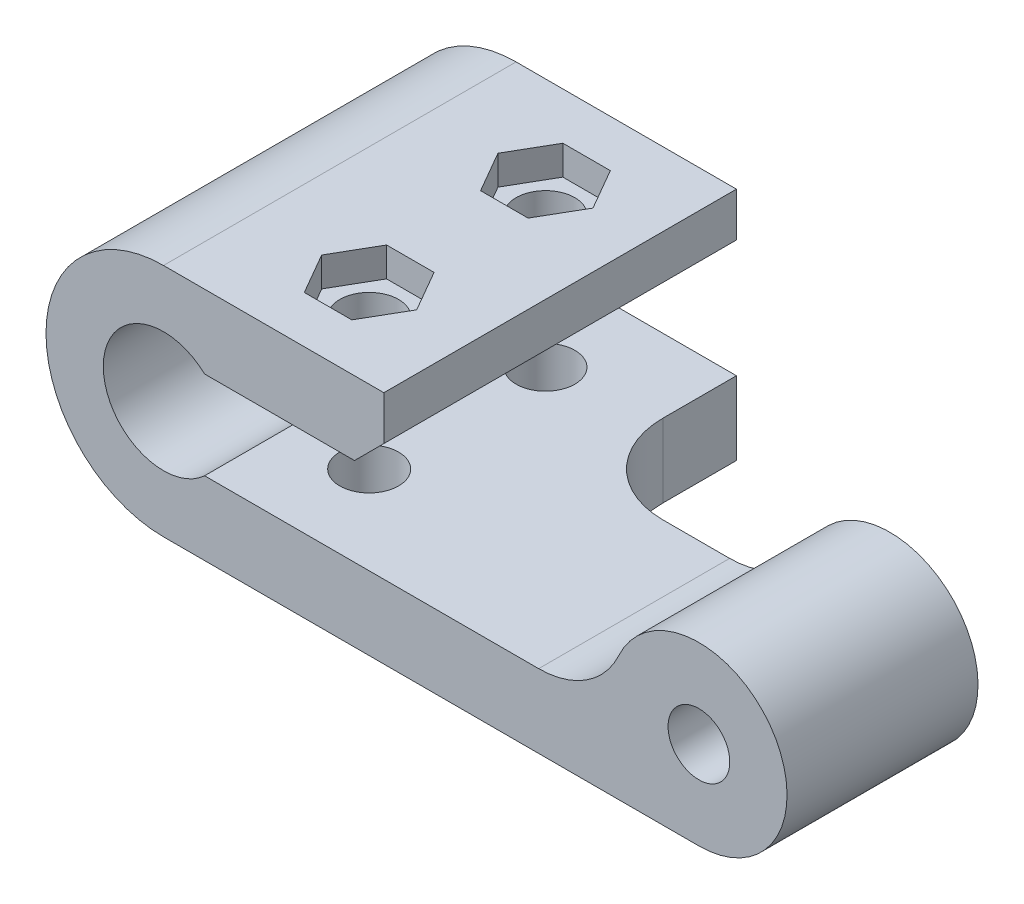
from build123d import *

# Parameters (mm, degrees)
SKETCH1_R           = 2.1
BOSS_EXTRUDE1_DEPTH = 24
SKETCH2_R           = 2
CUT_EXTRUDE1_DEPTH  = 17
CUT_EXTRUDE2_DEPTH  = 2
CUT_EXTRUDE3_DEPTH  = 5
CHAMFER1_SIZE       = 2


with BuildPart() as part:
    # Sketch1 → Boss-Extrude1 (new body)
    with BuildSketch(Plane.XY):
        with BuildLine():
            Line((2.794637722, 3), (15, 3))
            Line((15, 3), (15, 8))
            Line((15, 8), (0, 8))
            ThreePointArc((0, 8), (-8, 0), (0, -8))
            Line((0, -8), (36.445164288, -8))
            ThreePointArc((36.445164288, -8), (41.494916757, 1.240370349), (30.990808231, 0.5))
            ThreePointArc((30.990808231, 0.5), (28.776822523, -2.049752469), (25.536452174, -3))
            Line((25.536452174, -3), (2.794637722, -3))
            ThreePointArc((2.794637722, -3), (-4.1, 0), (2.794637722, 3))
        make_face()
        with Locations((36.445164288, -2)):
            Circle(SKETCH1_R, mode=Mode.SUBTRACT)
    extrude(amount=BOSS_EXTRUDE1_DEPTH)

    # Sketch2 → Cut-Extrude1 (cut, through all)
    with BuildSketch(Plane.XZ.offset(8)):
        with Locations((8, 18)):
            Circle(SKETCH2_R)
        with Locations((8, 6)):
            Circle(SKETCH2_R)
        with BuildLine():
            Line((15, 5), (15, 0))
            Line((15, 0), (45.871149595, 0))
            Line((45.871149595, 0), (45.871149595, 11))
            Line((45.871149595, 11), (21, 11))
            ThreePointArc((21, 11), (16.757359313, 9.242640687), (15, 5))
        make_face()
    extrude(amount=-CUT_EXTRUDE1_DEPTH, mode=Mode.SUBTRACT)

    # Sketch3 → Cut-Extrude2 (cut)
    with BuildSketch(Plane(origin=(0, 8, 0), x_dir=(-1, 0, 0), z_dir=(0, 1, 0))):
        Polygon((-9.616580754, 8.8), (-11.233161507, 6), (-9.616580754, 3.2), (-6.383419246, 3.2), (-4.766838493, 6), (-6.383419246, 8.8), align=None)
        Polygon((-9.616580754, 20.8), (-11.233161507, 18), (-9.616580754, 15.2), (-6.383419246, 15.2), (-4.766838493, 18), (-6.383419246, 20.8), align=None)
    extrude(amount=-CUT_EXTRUDE2_DEPTH, mode=Mode.SUBTRACT)

    # Sketch4 → Cut-Extrude3 (cut)
    with BuildSketch(Plane(origin=(0, 0, 11), x_dir=(-1, 0, 0), z_dir=(0, 0, -1))):
        Polygon((-34.424438346, 1.5), (-38.46589023, 1.5), (-40.486616173, -2), (-38.46589023, -5.5), (-34.424438346, -5.5), (-32.403712404, -2), align=None)
    extrude(amount=-CUT_EXTRUDE3_DEPTH, mode=Mode.SUBTRACT)

    # Chamfer1
    chamfer1_edges = [part.edges().sort_by_distance(p)[0] for p in [
        (15, 3, 12),
    ]]
    chamfer(chamfer1_edges, length=CHAMFER1_SIZE)


solid = part.part
